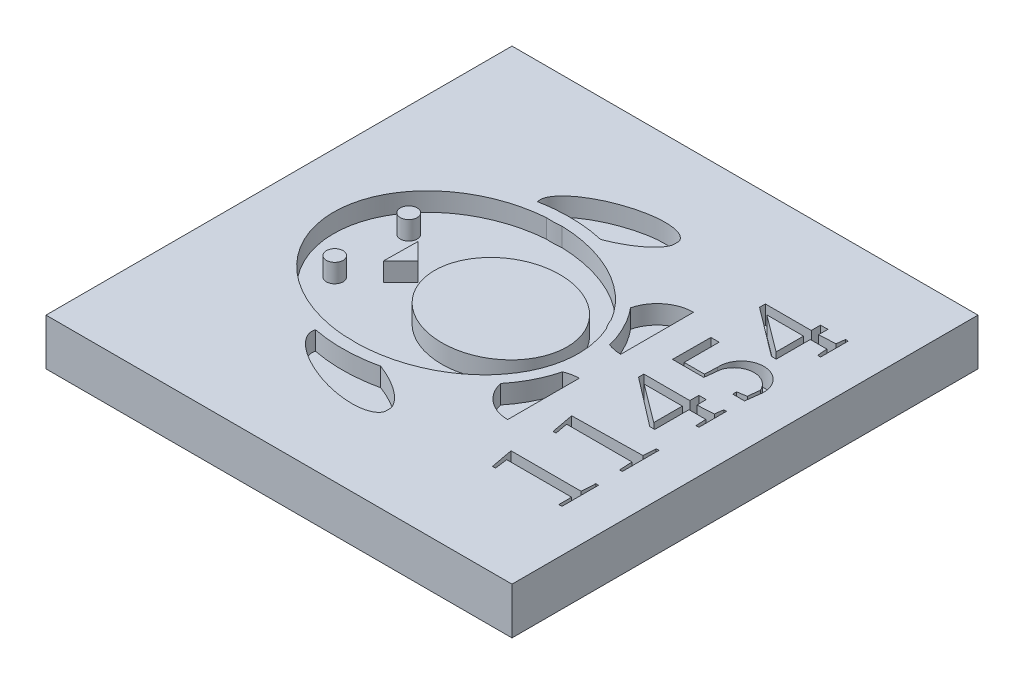
from build123d import *

# Parameters (mm, degrees)
SKETCH3_W           = 63.5
SKETCH3_H           = 63.5
BOSS_EXTRUDE1_DEPTH = 6.35
SKETCH4_R           = 1.143
CUT_EXTRUDE1_DEPTH  = 2.54
SKETCH6_W           = 63.5
SKETCH6_H           = 6.35
BOSS_EXTRUDE2_DEPTH = 7.62
SKETCH7_W           = 63.5
SKETCH7_H           = 6.35
CUT_EXTRUDE2_DEPTH  = 7.62
CUT_EXTRUDE4_DEPTH  = 2.54
BOSS_EXTRUDE3_DEPTH = 2.54


with BuildPart() as part:
    # Sketch3 → Boss-Extrude1 (new body)
    with BuildSketch(Plane(origin=(0, 0, 0), x_dir=(1, 0, 0), z_dir=(0, 1, 0))):
        Rectangle(SKETCH3_W, SKETCH3_H)
    extrude(amount=BOSS_EXTRUDE1_DEPTH)

    # Sketch4 → Cut-Extrude1 (cut)
    with BuildSketch(Plane(origin=(0, 6.35, 0), x_dir=(1, 0, 0), z_dir=(0, 1, 0))):
        with BuildLine():
            add(Edge.make_bspline(
                [(0.285093718, -13.901273866), (0.141147951, -13.887171676), (0, -13.876527186)],
                knots=[2.110140171, 2.110140171, 2.110140171, 2.153301949, 2.153301949, 2.153301949], degree=2, weights=[1, 0.999767142, 1]))
            add(Edge.make_bspline(
                [(0.285093718, -13.901273866), (1.728006496, -13.880738489), (3.145272016, -13.654183704)],
                knots=[4.729471643, 4.729471643, 4.729471643, 4.90197653, 4.90197653, 4.90197653], degree=2, weights=[1, 0.996282564, 1]))
            add(Edge.make_bspline(
                [(3.145272016, -13.654183704), (4.662818342, -13.411598686), (6.101104758, -12.94103951)],
                knots=[4.90197653, 4.90197653, 4.90197653, 5.086620295, 5.086620295, 5.086620295], degree=2, weights=[1, 0.995741361, 1]))
            add(Edge.make_bspline(
                [(6.101104758, -12.94103951), (8.398568731, -12.189386195), (10.336509093, -10.915933003)],
                knots=[5.086620295, 5.086620295, 5.086620295, 5.380275452, 5.380275452, 5.380275452], degree=2, weights=[1, 0.989240182, 1]))
            add(Edge.make_bspline(
                [(10.336509093, -10.915933003), (13.65255872, -8.736901046), (15.325235714, -5.506199261)],
                knots=[5.380275452, 5.380275452, 5.380275452, 5.875990185, 5.875990185, 5.875990185], degree=2, weights=[1, 0.969440293, 1]))
            add(Edge.make_bspline(
                [(15.325235714, -5.506199261), (16.689879283, -2.870450441), (16.689879283, 0)],
                knots=[5.875990185, 5.875990185, 5.875990185, 6.283185307, 6.283185307, 6.283185307], degree=2, weights=[1, 0.979345512, 1]))
            add(Edge.make_bspline(
                [(16.689879283, 0), (16.689879283, 2.47090436), (15.667871375, 4.790502426)],
                knots=[0, 0, 0, 0.351768553, 0.351768553, 0.351768553], degree=2, weights=[1, 0.984572194, 1]))
            ThreePointArc((15.667871375, 4.790502426), (15.246152328, 5.4662947), (14.938000428, 6.200858896))
            add(Edge.make_bspline(
                [(14.938000428, 6.200858896), (13.261554202, 9.00345036), (10.304720908, 10.936769548)],
                knots=[0.462290104, 0.462290104, 0.462290104, 0.905333422, 0.905333422, 0.905333422], degree=2, weights=[1, 0.975564248, 1]))
            add(Edge.make_bspline(
                [(10.304720908, 10.936769548), (8.379335669, 12.195678609), (6.101104758, 12.94103951)],
                knots=[0.905333422, 0.905333422, 0.905333422, 1.196565012, 1.196565012, 1.196565012], degree=2, weights=[1, 0.989416741, 1]))
            add(Edge.make_bspline(
                [(6.101104758, 12.94103951), (4.662818342, 13.411598686), (3.145272016, 13.654183704)],
                knots=[1.196565012, 1.196565012, 1.196565012, 1.381208778, 1.381208778, 1.381208778], degree=2, weights=[1, 0.995741361, 1]))
            add(Edge.make_bspline(
                [(3.145272016, 13.654183704), (1.847759672, 13.861595531), (0.527233781, 13.896363437)],
                knots=[1.381208778, 1.381208778, 1.381208778, 1.539201041, 1.539201041, 1.539201041], degree=2, weights=[1, 0.996881428, 1]))
            add(Edge.make_bspline(
                [(0, 13.846289536), (0.259050182, 13.865417717), (0.527233781, 13.896363437)],
                knots=[0.983131527, 0.983131527, 0.983131527, 1.062707397, 1.062707397, 1.062707397], degree=2, weights=[1, 0.999208565, 1]))
            add(Edge.make_bspline(
                [(-1.52471534, 13.845163355), (-0.825195404, 13.785357375), (0, 13.846289536)],
                knots=[0.730857997, 0.730857997, 0.730857997, 0.983131527, 0.983131527, 0.983131527], degree=2, weights=[1, 0.9920553, 1]))
            add(Edge.make_bspline(
                [(-1.52471534, 13.845163355), (-4.576425098, 13.611944607), (-7.329613451, 12.490815153)],
                knots=[1.662279564, 1.662279564, 1.662279564, 2.02546554, 2.02546554, 2.02546554], degree=2, weights=[1, 0.983557253, 1]))
            add(Edge.make_bspline(
                [(-7.329613451, 12.490815153), (-9.632246072, 11.553157092), (-11.491033182, 10.083139612)],
                knots=[2.02546554, 2.02546554, 2.02546554, 2.33021929, 2.33021929, 2.33021929], degree=2, weights=[1, 0.988413089, 1]))
            add(Edge.make_bspline(
                [(-11.491033182, 10.083139612), (-16.689879283, 5.971644216), (-16.689879283, 0)],
                knots=[2.33021929, 2.33021929, 2.33021929, 3.141592654, 3.141592654, 3.141592654], degree=2, weights=[1, 0.918831615, 1]))
            add(Edge.make_bspline(
                [(-16.689879283, 0), (-16.689879283, -5.971644216), (-11.491033182, -10.083139612)],
                knots=[3.141592654, 3.141592654, 3.141592654, 3.952966017, 3.952966017, 3.952966017], degree=2, weights=[1, 0.918831615, 1]))
            add(Edge.make_bspline(
                [(-11.491033182, -10.083139612), (-9.771897411, -11.442714154), (-7.666311338, -12.349762421)],
                knots=[3.952966017, 3.952966017, 3.952966017, 4.235138151, 4.235138151, 4.235138151], degree=2, weights=[1, 0.990063859, 1]))
            add(Edge.make_bspline(
                [(-7.666311338, -12.349762421), (-4.68680973, -13.633277639), (-1.343384924, -13.858190888)],
                knots=[4.235138151, 4.235138151, 4.235138151, 4.631810821, 4.631810821, 4.631810821], degree=2, weights=[1, 0.980395741, 1]))
            add(Edge.make_bspline(
                [(0, -13.876527186), (-0.717663487, -13.822405523), (-1.343384924, -13.858190888)],
                knots=[2.153301949, 2.153301949, 2.153301949, 2.371916233, 2.371916233, 2.371916233], degree=2, weights=[1, 0.99403192, 1]))
        make_face()
        with BuildLine():
            add(Edge.make_bspline(
                [(15.132094882, 0), (15.132094882, 8.047610254), (6.101104758, 8.047610254)],
                knots=[0, 0, 0, 1.570796327, 1.570796327, 1.570796327], degree=2, weights=[1, 0.707106781, 1]))
            add(Edge.make_bspline(
                [(6.101104758, -8.047610254), (15.132094882, -8.047610254), (15.132094882, 0)],
                knots=[4.71238898, 4.71238898, 4.71238898, 6.283185307, 6.283185307, 6.283185307], degree=2, weights=[1, 0.707106781, 1]))
            add(Edge.make_bspline(
                [(0, -5.933438019), (2.589256987, -8.047610254), (6.101104758, -8.047610254)],
                knots=[3.970645635, 3.970645635, 3.970645635, 4.71238898, 4.71238898, 4.71238898], degree=2, weights=[1, 0.932011781, 1]))
            add(Edge.make_bspline(
                [(-2.929885365, 0), (-2.929885365, -3.541136939), (0, -5.933438019)],
                knots=[3.141592654, 3.141592654, 3.141592654, 3.970645635, 3.970645635, 3.970645635], degree=2, weights=[1, 0.915307132, 1]))
            add(Edge.make_bspline(
                [(0, 5.933438019), (-2.929885365, 3.541136939), (-2.929885365, 0)],
                knots=[2.312539672, 2.312539672, 2.312539672, 3.141592654, 3.141592654, 3.141592654], degree=2, weights=[1, 0.915307132, 1]))
            add(Edge.make_bspline(
                [(6.101104758, 8.047610254), (2.589256987, 8.047610254), (0, 5.933438019)],
                knots=[1.570796327, 1.570796327, 1.570796327, 2.312539672, 2.312539672, 2.312539672], degree=2, weights=[1, 0.932011781, 1]))
        make_face(mode=Mode.SUBTRACT)
        with Locations((-11.491033182, 5.041569806)):
            Circle(SKETCH4_R, mode=Mode.SUBTRACT)
        with Locations((-11.491033182, -5.041569806)):
            Circle(SKETCH4_R, mode=Mode.SUBTRACT)
        Polygon((-7.46787673, 2.290157982), (-5.177718748, 0), (-7.530812997, -2.353094248), align=None, mode=Mode.SUBTRACT)
        with BuildLine():
            add(Edge.make_bspline(
                [(17.777546671, 3.152891994), (17.010423137, 6.306028067), (14.835880205, 8.937411908)],
                knots=[0.204808238, 0.204808238, 0.204808238, 0.614455544, 0.614455544, 0.614455544], degree=2, weights=[1, 0.979096868, 1]))
            ThreePointArc((17.777546671, 3.152891994), (18.697500427, 2.877644672), (19.653243047, 2.784735873))
            Line((19.653243047, 2.784735873), (19.653243047, 12.709264127))
            ThreePointArc((19.653243047, 12.709264127), (16.594082463, 11.654121932), (14.835880205, 8.937411908))
        make_face()
        with BuildLine():
            ThreePointArc((19.653243047, -2.873311927), (18.682716143, -2.970922849), (17.751064942, -3.259845681))
            add(Edge.make_bspline(
                [(14.906360437, -8.851509355), (16.985395233, -6.299215253), (17.751064942, -3.259845681)],
                knots=[5.675495318, 5.675495318, 5.675495318, 6.071325458, 6.071325458, 6.071325458], degree=2, weights=[1, 0.980478659, 1]))
            ThreePointArc((14.906360437, -8.851509355), (16.622582941, -11.563796399), (19.653243047, -12.620688073))
            Line((19.653243047, -12.620688073), (19.653243047, -2.873311927))
        make_face()
        with BuildLine():
            Line((10.336509093, -20.059933003), (10.336509093, -19.21927919))
            add(Edge.make_bspline(
                [(10.336509093, -19.21927919), (9.657796894, -16.850269205), (4.703244054, -14.973394659)],
                knots=[0.268390842, 0.268390842, 0.268390842, 1.488606212, 1.488606212, 1.488606212], degree=2, weights=[1, 0.819586324, 1]))
            add(Edge.make_bspline(
                [(3.145272016, -15.268147466), (3.931850515, -15.150026059), (4.703244054, -14.973394659)],
                knots=[4.886493376, 4.886493376, 4.886493376, 4.974408422, 4.974408422, 4.974408422], degree=2, weights=[1, 0.999034024, 1]))
            add(Edge.make_bspline(
                [(0, -15.502513285), (1.584614046, -15.502513285), (3.145272016, -15.268147466)],
                knots=[4.71238898, 4.71238898, 4.71238898, 4.886493376, 4.886493376, 4.886493376], degree=2, weights=[1, 0.99621335, 1]))
            add(Edge.make_bspline(
                [(-4.037000396, -15.114479333), (-2.044082286, -15.502513285), (0, -15.502513285)],
                knots=[4.488176971, 4.488176971, 4.488176971, 4.71238898, 4.71238898, 4.71238898], degree=2, weights=[1, 0.9937227, 1]))
            add(Edge.make_bspline(
                [(-4.037000396, -15.114479333), (-4.796171568, -17.179730474), (0, -19.538864094)],
                knots=[3.132654716, 3.132654716, 3.132654716, 4.3982742, 4.3982742, 4.3982742], degree=2, weights=[1, 0.806368976, 1]))
            add(Edge.make_bspline(
                [(0, -19.538864094), (9.000289167, -23.965912724), (10.336509093, -20.059933003)],
                knots=[4.3982742, 4.3982742, 4.3982742, 6.283185307, 6.283185307, 6.283185307], degree=2, weights=[1, 0.587803247, 1]))
        make_face()
        with BuildLine():
            add(Edge.make_bspline(
                [(4.742421852, 14.964383768), (9.619611108, 16.843311628), (10.304720908, 19.212085025)],
                knots=[1.656183086, 1.656183086, 1.656183086, 2.866729076, 2.866729076, 2.866729076], degree=2, weights=[1, 0.822346798, 1]))
            Line((10.304720908, 19.212085025), (10.304720908, 20.080769548))
            add(Edge.make_bspline(
                [(10.304720908, 20.080769548), (8.943802448, 24.008098033), (0, 19.55518613)],
                knots=[3.141592654, 3.141592654, 3.141592654, 5.025190203, 5.025190203, 5.025190203], degree=2, weights=[1, 0.588334457, 1]))
            add(Edge.make_bspline(
                [(0, 19.55518613), (-4.734610871, 17.197933135), (-4.014176875, 15.118910007)],
                knots=[5.025190203, 5.025190203, 5.025190203, 6.283185307, 6.283185307, 6.283185307], degree=2, weights=[1, 0.808617689, 1]))
            add(Edge.make_bspline(
                [(0, 15.502513285), (-2.032231805, 15.502513285), (-4.014176875, 15.118910007)],
                knots=[1.570796327, 1.570796327, 1.570796327, 1.793719247, 1.793719247, 1.793719247], degree=2, weights=[1, 0.9937946, 1]))
            add(Edge.make_bspline(
                [(3.145272016, 15.268147466), (1.584614046, 15.502513285), (0, 15.502513285)],
                knots=[1.396691931, 1.396691931, 1.396691931, 1.570796327, 1.570796327, 1.570796327], degree=2, weights=[1, 0.99621335, 1]))
            add(Edge.make_bspline(
                [(4.742421852, 14.964383768), (3.951870677, 15.147019609), (3.145272016, 15.268147466)],
                knots=[1.306542245, 1.306542245, 1.306542245, 1.396691931, 1.396691931, 1.396691931], degree=2, weights=[1, 0.998984301, 1]))
        make_face()
    extrude(amount=-CUT_EXTRUDE1_DEPTH, mode=Mode.SUBTRACT)

    # Sketch6 → Boss-Extrude2 (add)
    with BuildSketch(Plane(origin=(31.75, 0, 0), x_dir=(0, 0, -1), z_dir=(1, 0, 0))):
        with Locations((0, 3.175)):
            Rectangle(SKETCH6_W, SKETCH6_H)
    extrude(amount=BOSS_EXTRUDE2_DEPTH)

    # Sketch7 → Cut-Extrude2 (cut)
    with BuildSketch(Plane.ZY.offset(31.75)):
        with Locations((0, 3.175)):
            Rectangle(SKETCH7_W, SKETCH7_H)
    extrude(amount=-CUT_EXTRUDE2_DEPTH, mode=Mode.SUBTRACT)

    # Sketch12 → Cut-Extrude4 (cut)
    with BuildSketch(Plane(origin=(0, 6.35, 0), x_dir=(1, 0, 0), z_dir=(0, 1, 0))):
        Polygon((33.593246218, -19.151097585), (33.166488647, -19.186254677), (33.166488647, -17.423003496), (24.320701962, -17.423003496), (24.549320527, -19.186254677), (24.145614866, -19.186254677), (23.565290148, -16.077284432), (33.125192764, -16.077284432), (33.226133784, -14.181742501), (33.593246218, -14.181742501), align=None)
        Polygon((23.565290148, -7.815737602), (24.145614866, -10.934989892), (24.549320527, -10.934989892), (24.217440727, -9.151132002), (33.125192764, -9.151132002), (33.226133784, -10.934989892), (33.593246218, -10.934989892), (33.593246218, -5.950075503), (33.226133784, -5.950075503), (33.125192764, -7.650764741), align=None)
        Polygon((23.565290148, 1.297558562), (30.159561553, -3.768846562), (30.841271678, -3.768846562), (30.841271678, 0.896707068), (33.125192764, 0.896707068), (33.204725587, -0.508819195), (33.593246218, -0.508819195), (33.593246218, 3.26205848), (33.226133784, 3.26205848), (33.071091975, 2.113210752), (30.841271678, 1.987034594), (30.819268908, 3.26205848), (29.820109802, 3.26205848), (29.820109802, 2.028035435), (23.565290148, 2.028035435), align=None)
        with BuildLine():
            Line((33.872049171, 7.876144547), (33.593246218, 5.712328768))
            Line((33.593246218, 5.712328768), (31.982166596, 5.712328768))
            Line((31.982166596, 5.712328768), (31.982166596, 6.244713088))
            Line((31.982166596, 6.244713088), (33.226133784, 6.451244619))
            Line((33.226133784, 6.451244619), (33.413844217, 8.063251683))
            ThreePointArc((33.413844217, 8.063251683), (30.75644662, 9.711117804), (28.28105604, 7.800707843))
            Line((28.28105604, 7.800707843), (28.037874389, 5.712328768))
            Line((28.037874389, 5.712328768), (23.776681836, 5.712328768))
            Line((23.776681836, 5.712328768), (23.806900714, 10.919695022))
            Line((23.806900714, 10.919695022), (24.932231466, 10.919695022))
            Line((24.932231466, 10.919695022), (24.932231466, 6.145844125))
            Line((24.932231466, 6.145844125), (27.698371943, 6.145844125))
            Line((27.698371943, 6.145844125), (27.773583408, 7.876144547))
            ThreePointArc((27.773583408, 7.876144547), (30.822816289, 11.118219809), (33.872049171, 7.876144547))
        make_face()
        Polygon((33.593246218, 16.074001839), (33.593246218, 19.846718856), (33.226133784, 19.846718856), (33.077450188, 18.69277157), (30.822816289, 18.578870502), (30.822816289, 19.846718856), (29.820109802, 19.829472614), (29.820109802, 18.578870502), (23.565290148, 18.578870502), (23.565290148, 17.784563952), (30.159561553, 12.808048358), (30.822816289, 12.808048358), (30.822816289, 17.442568397), (33.077165472, 17.442568397), (33.195656071, 16.073977189), align=None)
    extrude(amount=-CUT_EXTRUDE4_DEPTH, mode=Mode.SUBTRACT)

    # Sketch13 → Boss-Extrude3 (add)
    with BuildSketch(Plane(origin=(0, 3.81, 0), x_dir=(1, 0, 0), z_dir=(0, 1, 0))):
        Polygon((29.958766112, 0.866227004), (29.958766112, -3.019488508), (24.76950169, 0.866227004), align=None)
        Polygon((29.958766112, 17.388049953), (29.958766112, 13.650399411), (24.967238317, 17.388049953), align=None)
    extrude(amount=BOSS_EXTRUDE3_DEPTH)


solid = part.part
